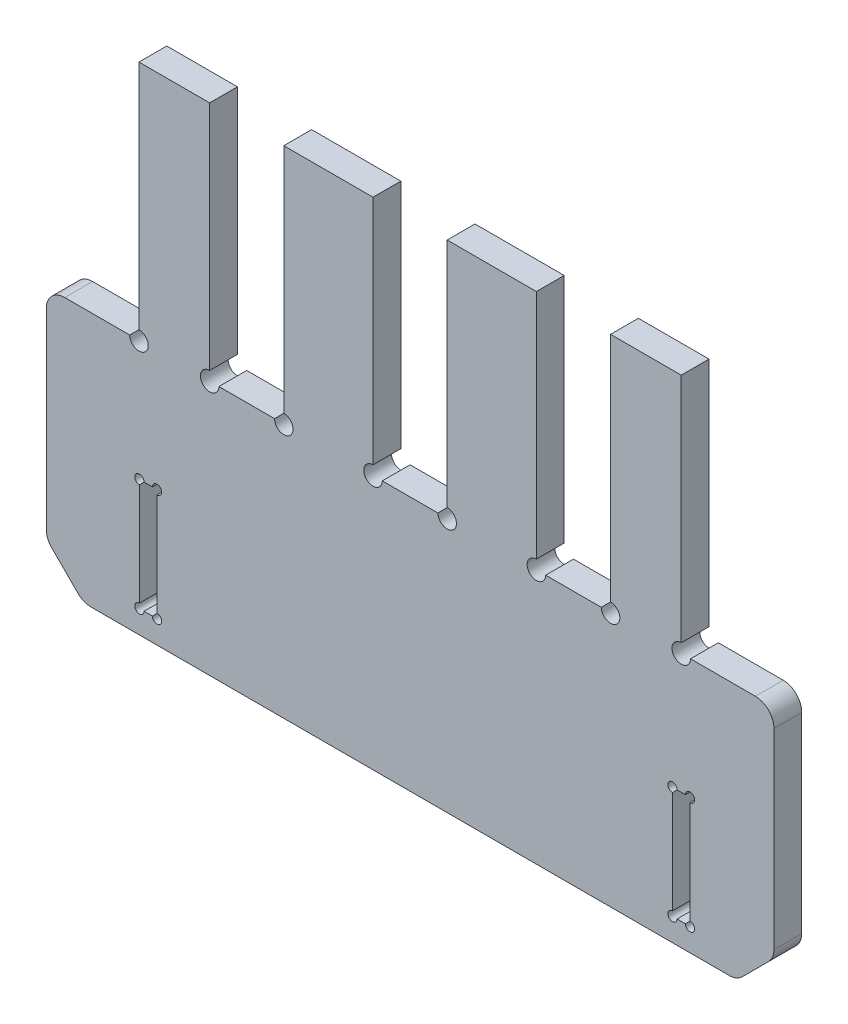
from build123d import *

# Parameters (mm, degrees)
SKETCH_1_W          = 78.5
SKETCH_1_H          = 53.5
EXTRUDE_1_DEPTH     = 3
SKETCH_2_W          = 2
SKETCH_2_H          = 12
CUT_EXTRUDE_1_DEPTH = 5
SKETCH_3_W          = 8
SKETCH_3_H          = 26.5
CUT_EXTRUDE_2_DEPTH = 4
SKETCH_7_W          = 2
SKETCH_7_H          = 26.5
CUT_EXTRUDE_3_DEPTH = 10
SKETCH_8_W          = 2
SKETCH_8_H          = 12
CUT_EXTRUDE_4_DEPTH = 10
SKETCH_9_W          = 2.06
SKETCH_9_H          = 12.06
SKETCH_9_W_2        = 2
SKETCH_9_H_2        = 12
CUT_EXTRUDE_5_DEPTH = 10
CHAMFER_1_SIZE      = 4
SKETCH_11_W         = 78.5
SKETCH_11_H         = 3
EXTRUDE_2_DEPTH     = 0.5
FILLET_2_R          = 2
SKETCH_14_W         = 0.08
SKETCH_14_H         = 12.06
EXTRUDE_3_DEPTH     = 3
SKETCH_15_W         = 0.08
SKETCH_15_H         = 12.06
EXTRUDE_4_DEPTH     = 3
SKETCH_16_R         = 0.5
CUT_EXTRUDE_6_DEPTH = 10
SKETCH_17_R         = 1
CUT_EXTRUDE_7_DEPTH = 10


with BuildPart() as part:
    # 草图1 → 凸台-拉伸1 (new body)
    with BuildSketch(Plane.XY):
        Rectangle(SKETCH_1_W, SKETCH_1_H)
    extrude(amount=EXTRUDE_1_DEPTH)

    # 草图2 → 切除-拉伸1 (cut)
    with BuildSketch(Plane(origin=(0, 0, 0), x_dir=(-1, 0, 0), z_dir=(0, 0, -1))):
        with Locations((-29.25, -18.25)):
            Rectangle(SKETCH_2_W, SKETCH_2_H)
    extrude(amount=-CUT_EXTRUDE_1_DEPTH, mode=Mode.SUBTRACT)

    # 草图3 → 切除-拉伸2 (cut, through all)
    with BuildSketch(Plane(origin=(0, 0, 0), x_dir=(-1, 0, 0), z_dir=(0, 0, -1))):
        with Locations((-17.625, 13.5)):
            Rectangle(SKETCH_3_W, SKETCH_3_H)
        with Locations((35.25, 13.5)):
            Rectangle(SKETCH_3_W, SKETCH_3_H)
        with Locations((17.625, 13.5)):
            Rectangle(SKETCH_3_W, SKETCH_3_H)
        with Locations((0, 13.5)):
            Rectangle(SKETCH_3_W, SKETCH_3_H)
        with Locations((-35.25, 13.5)):
            Rectangle(SKETCH_3_W, SKETCH_3_H)
    extrude(amount=-CUT_EXTRUDE_2_DEPTH, mode=Mode.SUBTRACT)

    # 草图7 → 切除-拉伸3 (cut)
    with BuildSketch(Plane(origin=(0, 0, 0), x_dir=(-1, 0, 0), z_dir=(0, 0, -1))):
        with Locations((30.25, 13.5)):
            Rectangle(SKETCH_7_W, SKETCH_7_H)
        with Locations((-30.25, 13.5)):
            Rectangle(SKETCH_7_W, SKETCH_7_H)
    extrude(amount=-CUT_EXTRUDE_3_DEPTH, mode=Mode.SUBTRACT)

    # 草图8 → 切除-拉伸4 (cut)
    with BuildSketch(Plane(origin=(0, 0, 0), x_dir=(-1, 0, 0), z_dir=(0, 0, -1))):
        with Locations((28.25, -18.25)):
            Rectangle(SKETCH_8_W, SKETCH_8_H)
    extrude(amount=-CUT_EXTRUDE_4_DEPTH, mode=Mode.SUBTRACT)

    # 草图9 → 切除-拉伸5 (cut)
    with BuildSketch(Plane(origin=(0, 0, 0), x_dir=(-1, 0, 0), z_dir=(0, 0, -1))):
        with Locations((28.25, -18.25)):
            Rectangle(SKETCH_9_W, SKETCH_9_H)
        with Locations((28.25, -18.25)):
            Rectangle(SKETCH_9_W_2, SKETCH_9_H_2, mode=Mode.SUBTRACT)
        with Locations((-29.25, -18.25)):
            Rectangle(SKETCH_9_W, SKETCH_9_H)
        with Locations((-29.25, -18.25)):
            Rectangle(SKETCH_9_W_2, SKETCH_9_H_2, mode=Mode.SUBTRACT)
    extrude(amount=-CUT_EXTRUDE_5_DEPTH, mode=Mode.SUBTRACT)

    # 倒角1
    chamfer_1_edges = [part.edges().sort_by_distance(p)[0] for p in [
        (39.25, -26.75, 1.5),
        (-39.25, -26.75, 1.5),
    ]]
    chamfer(chamfer_1_edges, length=CHAMFER_1_SIZE)

    # 草图11 → 凸台-拉伸2 (add)
    with BuildSketch(Plane(origin=(0, 0.25, 0), x_dir=(1, 0, 0), z_dir=(0, 1, 0))):
        with Locations((0, -1.5)):
            Rectangle(SKETCH_11_W, SKETCH_11_H)
    extrude(amount=EXTRUDE_2_DEPTH)

    # 圆角2
    fillet_2_edges = [part.edges().sort_by_distance(p)[0] for p in [
        (35.25, -26.75, 1.5),
        (-35.25, -26.75, 1.5),
        (-39.25, -22.75, 1.5),
        (39.25, -22.75, 1.5),
        (-39.25, 0.75, 1.5),
        (39.25, 0.75, 1.5),
    ]]
    fillet(fillet_2_edges, radius=FILLET_2_R)

    # 草图14 → 凸台-拉伸3 (add)
    with BuildSketch(Plane(origin=(0, 0, 0), x_dir=(-1, 0, 0), z_dir=(0, 0, -1))):
        with Locations((-30.24, -18.25)):
            Rectangle(SKETCH_14_W, SKETCH_14_H)
        with Locations((-28.26, -18.25)):
            Rectangle(SKETCH_14_W, SKETCH_14_H)
    extrude(amount=-EXTRUDE_3_DEPTH)

    # 草图15 → 凸台-拉伸4 (add)
    with BuildSketch(Plane(origin=(0, 0, 0), x_dir=(-1, 0, 0), z_dir=(0, 0, -1))):
        with Locations((27.26, -18.25)):
            Rectangle(SKETCH_15_W, SKETCH_15_H)
        with Locations((29.24, -18.25)):
            Rectangle(SKETCH_15_W, SKETCH_15_H)
    extrude(amount=-EXTRUDE_4_DEPTH)

    # 草图16 → 切除-拉伸6 (cut)
    with BuildSketch(Plane(origin=(0, 0, 0), x_dir=(-1, 0, 0), z_dir=(0, 0, -1))):
        with Locations((-30.2, -12.22)):
            Circle(SKETCH_16_R)
        with Locations((-28.3, -12.22)):
            Circle(SKETCH_16_R)
        with Locations((-30.2, -24.28)):
            Circle(SKETCH_16_R)
        with Locations((-28.3, -24.28)):
            Circle(SKETCH_16_R)
        with Locations((27.3, -12.22)):
            Circle(SKETCH_16_R)
        with Locations((29.2, -12.22)):
            Circle(SKETCH_16_R)
        with Locations((27.3, -24.28)):
            Circle(SKETCH_16_R)
        with Locations((29.2, -24.28)):
            Circle(SKETCH_16_R)
    extrude(amount=-CUT_EXTRUDE_6_DEPTH, mode=Mode.SUBTRACT)

    # 草图17 → 切除-拉伸7 (cut)
    with BuildSketch(Plane(origin=(0, 0, 0), x_dir=(-1, 0, 0), z_dir=(0, 0, -1))):
        with Locations((-29.25, 0.75)):
            Circle(SKETCH_17_R)
        with Locations((-21.625, 0.75)):
            Circle(SKETCH_17_R)
        with Locations((-13.625, 0.75)):
            Circle(SKETCH_17_R)
        with Locations((-4, 0.75)):
            Circle(SKETCH_17_R)
        with Locations((4, 0.75)):
            Circle(SKETCH_17_R)
        with Locations((13.625, 0.75)):
            Circle(SKETCH_17_R)
        with Locations((21.625, 0.75)):
            Circle(SKETCH_17_R)
        with Locations((29.25, 0.75)):
            Circle(SKETCH_17_R)
    extrude(amount=-CUT_EXTRUDE_7_DEPTH, mode=Mode.SUBTRACT)


solid = part.part
